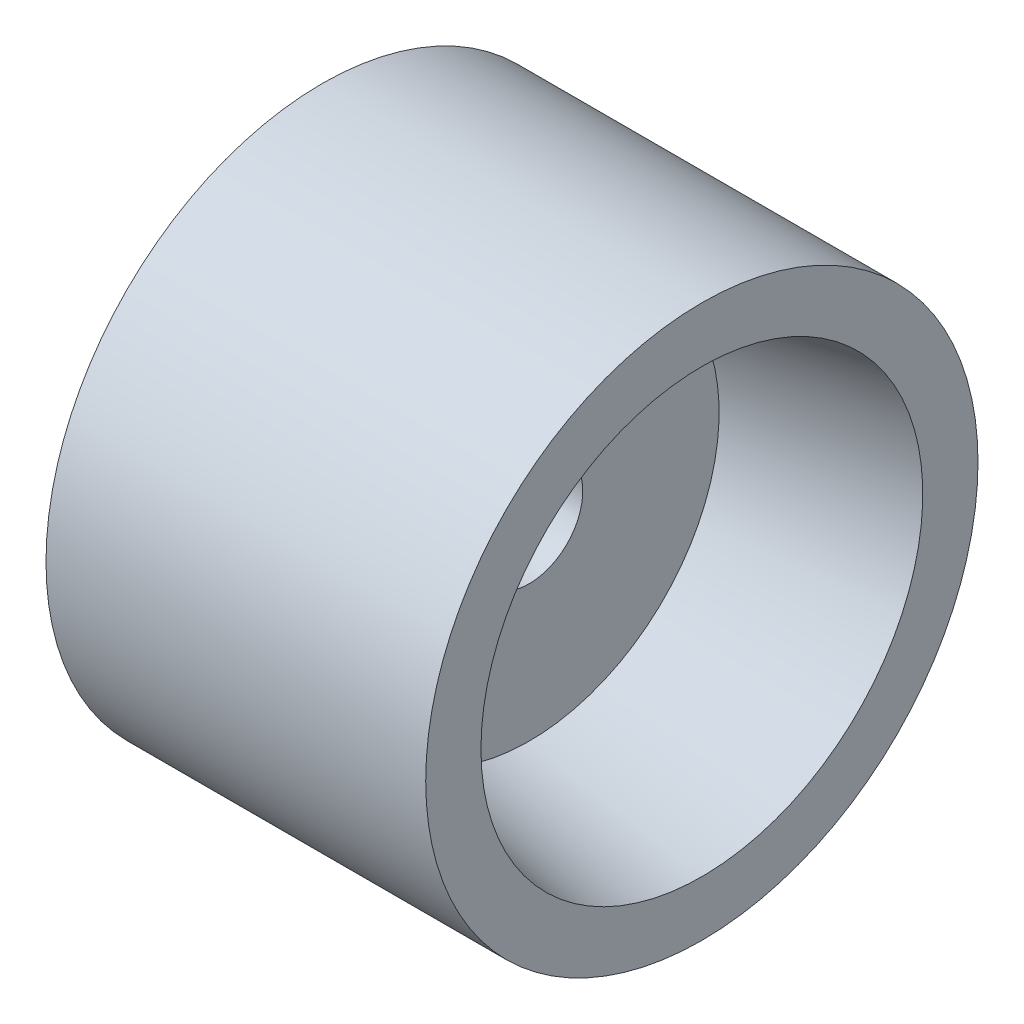
from build123d import *


with BuildPart() as part:
    # Skizze1 → Rotation1 (revolve)
    with BuildSketch(Plane.XY):
        Polygon((11, 1.55), (8, 1.55), (8, 4), (4, 4), (4, 5.5), (5, 6.4), (5, 8), (16, 8), (16, 6.4), (11, 5.5), align=None)
    revolve(axis=Axis((0, 0, 0), (1, 0, 0)))


solid = part.part
